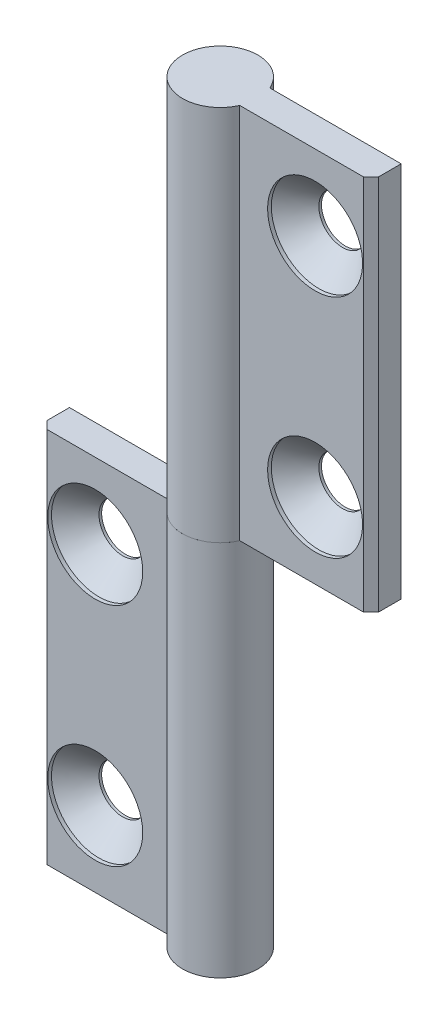
from build123d import *

# Parameters (mm, degrees)
EXTRUDE_1_DEPTH            = 25
HOLE_WIZARD_M61_AT_2_COUNT = 2
HOLE_WIZARD_M61_AT_2_PITCH = 30
PATTERN_CIRCULAR_1_COUNT   = 2


with BuildPart() as part:
    # Эскиз1 → Бобышка-Вытянуть1 (new body, symmetric)
    with BuildSketch(Plane(origin=(0, 0, 0), x_dir=(1, 0, 0), z_dir=(0, 1, 0))):
        with BuildLine():
            Line((-4.582575695, 2), (-22, 2))
            Line((-22, 2), (-22, -1))
            Line((-22, -1), (-21, -2))
            Line((-21, -2), (-4.582575695, -2))
            ThreePointArc((-4.582575695, -2), (5, 0), (-4.582575695, 2))
        make_face()
    extrude(amount=EXTRUDE_1_DEPTH, both=True)

    # Эскиз6 → Зенковка для винта с полупотайной головкой M61 (revolve, cut)
    with BuildSketch(Plane(origin=(-14.582575695, 15, 2), x_dir=(0, -1, 0), z_dir=(1, 0, 0))):
        Polygon((0, 0), (0, 7), (3.15, 7), (3.15, 3.65), (6.3, 0.5), (6.3, 0), align=None)
    hole_wizard_m61 = revolve(axis=Axis((-14.582575695, 15, 8.35), (0, 0, -1)), mode=Mode.SUBTRACT)

    # Зенковка для винта с полупотайной головкой M61 at 2: Зенковка для винта с полупотайной головкой M61 ×2
    with Locations(*[(0, -i * HOLE_WIZARD_M61_AT_2_PITCH, 0) for i in range(1, HOLE_WIZARD_M61_AT_2_COUNT)]):
        add(hole_wizard_m61, mode=Mode.SUBTRACT)


with BuildPart() as pattern_circular_1_1:
    # Круговой массив1: pattern copy
    add(part.part.rotate(Axis((0, 25, 0), (0, 0, 1)), 1 * 360 / PATTERN_CIRCULAR_1_COUNT))


solid = Compound([part.part, pattern_circular_1_1.part])
